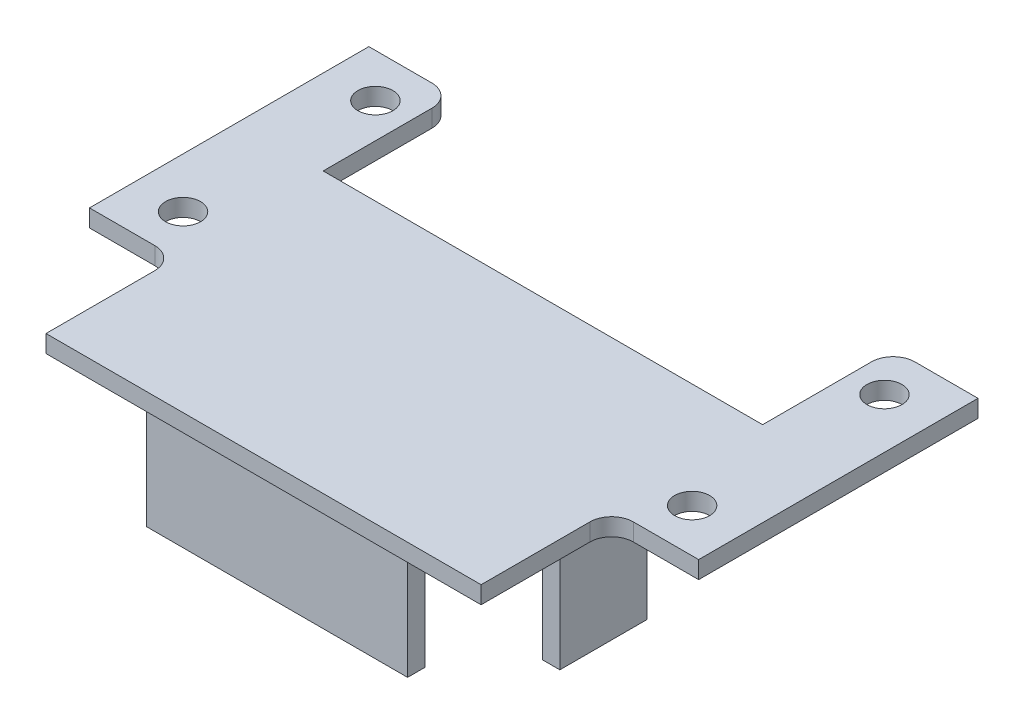
from build123d import *

# Parameters (mm, degrees)
SKETCH1_R           = 2.5527
BOSS_EXTRUDE1_DEPTH = 2.54
SKETCH7_W           = 88.9
SKETCH7_H           = 19.05
BOSS_EXTRUDE2_DEPTH = 2.54
SKETCH6_W           = 38.1
SKETCH6_H           = 2.54
SKETCH6_W_2         = 2.54
SKETCH6_H_2         = 12.7
BOSS_EXTRUDE3_DEPTH = 16.51
CUT_EXTRUDE1_DEPTH  = 3.54


with BuildPart() as part:
    # Sketch1 → Boss-Extrude1 (new body)
    with BuildSketch(Plane(origin=(0, 0, 0), x_dir=(1, 0, 0), z_dir=(0, 1, 0))):
        with BuildLine():
            Line((44.45, -20.3835), (-44.45, -20.3835))
            Line((-44.45, -20.3835), (-44.45, 20.3835))
            Line((-44.45, 20.3835), (-35.2425, 20.3835))
            ThreePointArc((-35.2425, 20.3835), (-32.99743597, 19.45356403), (-32.0675, 17.2085))
            Line((-32.0675, 17.2085), (-32.0675, 1.3335))
            Line((-32.0675, 1.3335), (32.0675, 1.3335))
            Line((32.0675, 1.3335), (32.0675, 17.2085))
            ThreePointArc((32.0675, 17.2085), (32.99743597, 19.45356403), (35.2425, 20.3835))
            Line((35.2425, 20.3835), (44.45, 20.3835))
            Line((44.45, 20.3835), (44.45, -20.3835))
        make_face()
        with Locations((37.1475, -14.0335)):
            Circle(SKETCH1_R, mode=Mode.SUBTRACT)
        with Locations((37.1475, 14.0335)):
            Circle(SKETCH1_R, mode=Mode.SUBTRACT)
        with Locations((-37.1475, -14.0335)):
            Circle(SKETCH1_R, mode=Mode.SUBTRACT)
        with Locations((-37.1475, 14.0335)):
            Circle(SKETCH1_R, mode=Mode.SUBTRACT)
    extrude(amount=BOSS_EXTRUDE1_DEPTH)

    # Sketch7 → Boss-Extrude2 (add)
    with BuildSketch(Plane(origin=(0, 2.54, 0), x_dir=(1, 0, 0), z_dir=(0, 1, 0))):
        with Locations((0, -29.9085)):
            Rectangle(SKETCH7_W, SKETCH7_H)
    extrude(amount=-BOSS_EXTRUDE2_DEPTH)

    # Sketch6 → Boss-Extrude3 (add)
    with BuildSketch(Plane(origin=(0, 0, 0), x_dir=(-1, 0, 0), z_dir=(0, -1, 0))):
        with Locations((0, -36.195)):
            Rectangle(SKETCH6_W, SKETCH6_H)
        with Locations((0, -1.905)):
            Rectangle(SKETCH6_W, SKETCH6_H)
        with Locations((27.94, -19.05)):
            Rectangle(SKETCH6_W_2, SKETCH6_H_2)
        with Locations((-27.94, -19.05)):
            Rectangle(SKETCH6_W_2, SKETCH6_H_2)
    extrude(amount=BOSS_EXTRUDE3_DEPTH)

    # Sketch8 → Cut-Extrude1 (cut, through all)
    with BuildSketch(Plane.XZ):
        with BuildLine():
            Line((-44.45, 39.4335), (-31.75, 39.4335))
            Line((-31.75, 39.4335), (-31.75, 23.5585))
            ThreePointArc((-31.75, 23.5585), (-32.67993597, 21.31343597), (-34.925, 20.3835))
            Line((-34.925, 20.3835), (-44.45, 20.3835))
            Line((-44.45, 20.3835), (-44.45, 39.4335))
        make_face()
        with BuildLine():
            Line((44.45, 20.3835), (34.925, 20.3835))
            ThreePointArc((34.925, 20.3835), (32.67993597, 21.31343597), (31.75, 23.5585))
            Line((31.75, 23.5585), (31.75, 39.4335))
            Line((31.75, 39.4335), (44.45, 39.4335))
            Line((44.45, 39.4335), (44.45, 20.3835))
        make_face()
    extrude(amount=-CUT_EXTRUDE1_DEPTH, mode=Mode.SUBTRACT)


solid = part.part
